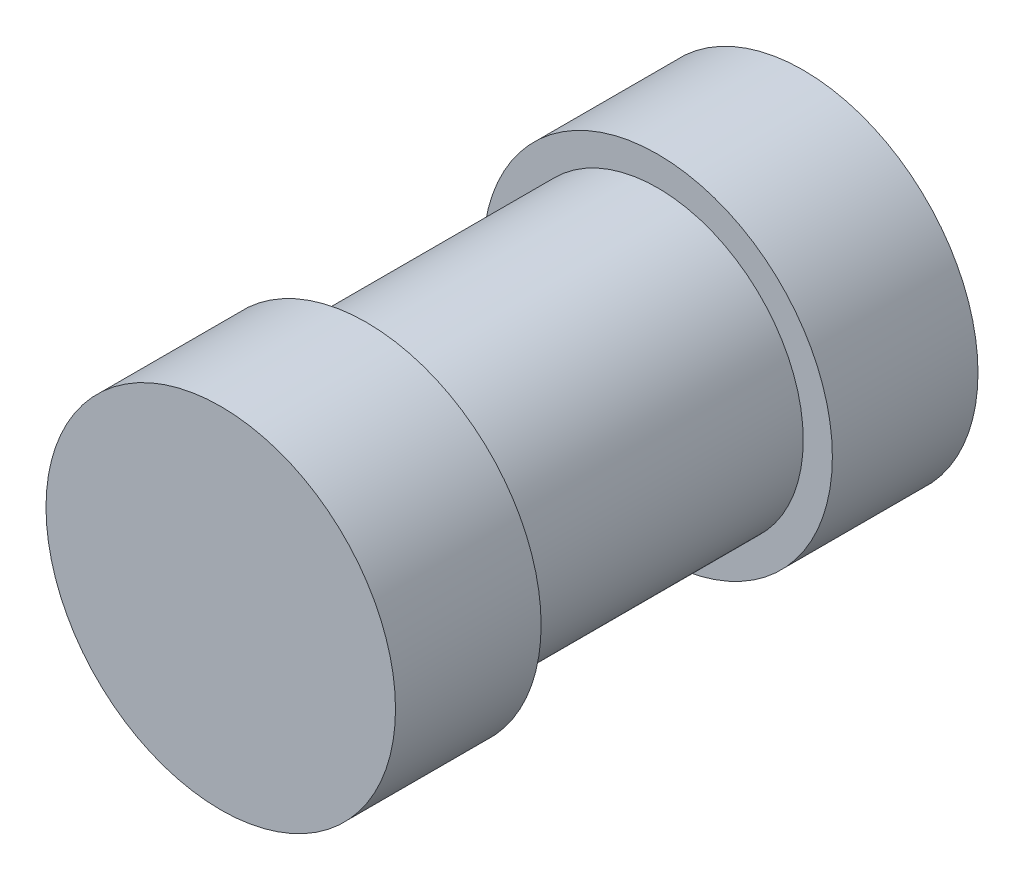
from build123d import *

# Parameters (mm, degrees)
SKETCH1_R           = 3.175
BOSS_EXTRUDE1_DEPTH = 6.35
SKETCH2_R           = 3.81
BOSS_EXTRUDE2_DEPTH = 3.175
SKETCH3_R           = 3.81
BOSS_EXTRUDE3_DEPTH = 3.175


with BuildPart() as part:
    # Sketch1 → Boss-Extrude1 (new body)
    with BuildSketch(Plane.XY):
        Circle(SKETCH1_R)
    extrude(amount=BOSS_EXTRUDE1_DEPTH)

    # Sketch2 → Boss-Extrude2 (add)
    with BuildSketch(Plane.XY.offset(6.35)):
        Circle(SKETCH2_R)
    extrude(amount=BOSS_EXTRUDE2_DEPTH)

    # Sketch3 → Boss-Extrude3 (add)
    with BuildSketch(Plane(origin=(0, 0, 0), x_dir=(-1, 0, 0), z_dir=(0, 0, -1))):
        Circle(SKETCH3_R)
    extrude(amount=BOSS_EXTRUDE3_DEPTH)


solid = part.part
